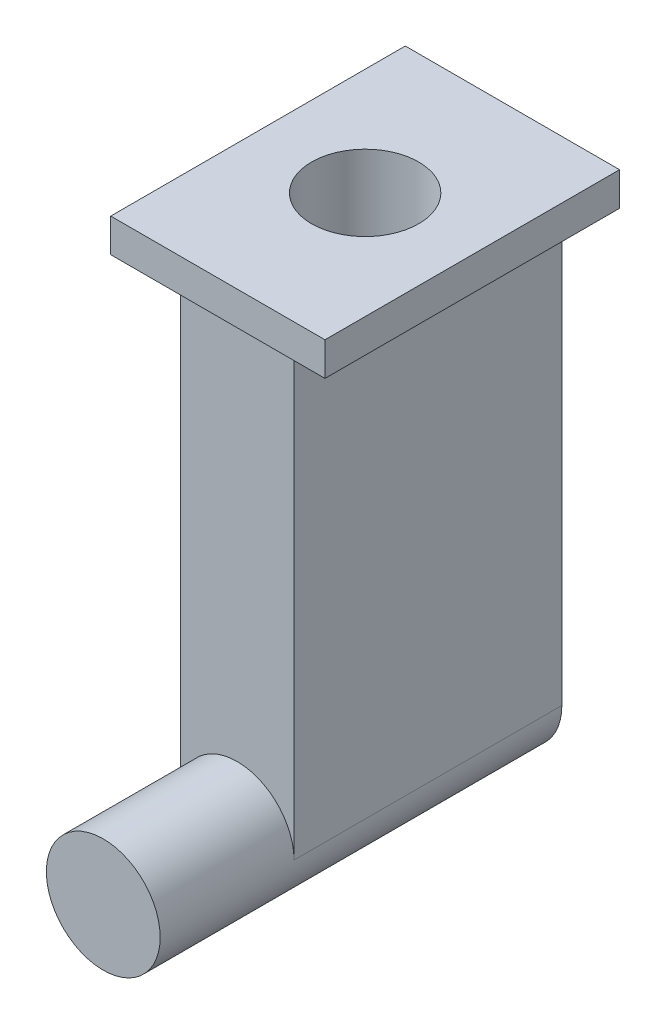
from build123d import *

# Parameters (mm, degrees)
SKETCH1_R           = 42.5
BOSS_EXTRUDE1_DEPTH = 100
BOSS_EXTRUDE2_DEPTH = 200
SKETCH5_W           = 160
SKETCH5_H           = 220
BOSS_EXTRUDE4_DEPTH = 12.5
SKETCH6_R           = 40
CUT_EXTRUDE1_DEPTH  = 250


with BuildPart() as part:
    # Sketch1 → Boss-Extrude1 (new body)
    with BuildSketch(Plane.XY):
        Circle(SKETCH1_R)
    extrude(amount=-BOSS_EXTRUDE1_DEPTH)

    # Sketch2 → Boss-Extrude2 (add)
    with BuildSketch(Plane(origin=(0, 0, -100), x_dir=(-1, 0, 0), z_dir=(0, 0, -1))):
        with BuildLine():
            Line((-42.5, 350), (42.5, 350))
            Line((42.5, 350), (42.5, 0))
            ThreePointArc((42.5, 0), (0, -42.5), (-42.5, 0))
            Line((-42.5, 0), (-42.5, 350))
        make_face()
    extrude(amount=BOSS_EXTRUDE2_DEPTH)

    # Sketch5 → Boss-Extrude4 (add, symmetric)
    with BuildSketch(Plane(origin=(0, 350, 104.422680699), x_dir=(1, 0, 0), z_dir=(0, 1, 0))):
        with Locations((0, 300)):
            Rectangle(SKETCH5_W, SKETCH5_H)
    extrude(amount=BOSS_EXTRUDE4_DEPTH, both=True)

    # Sketch6 → Cut-Extrude1 (cut)
    with BuildSketch(Plane(origin=(0, 362.5, 104.422680699), x_dir=(1, 0, 0), z_dir=(0, 1, 0))):
        with Locations((0, 300)):
            Circle(SKETCH6_R)
    extrude(amount=-CUT_EXTRUDE1_DEPTH, mode=Mode.SUBTRACT)


solid = part.part
